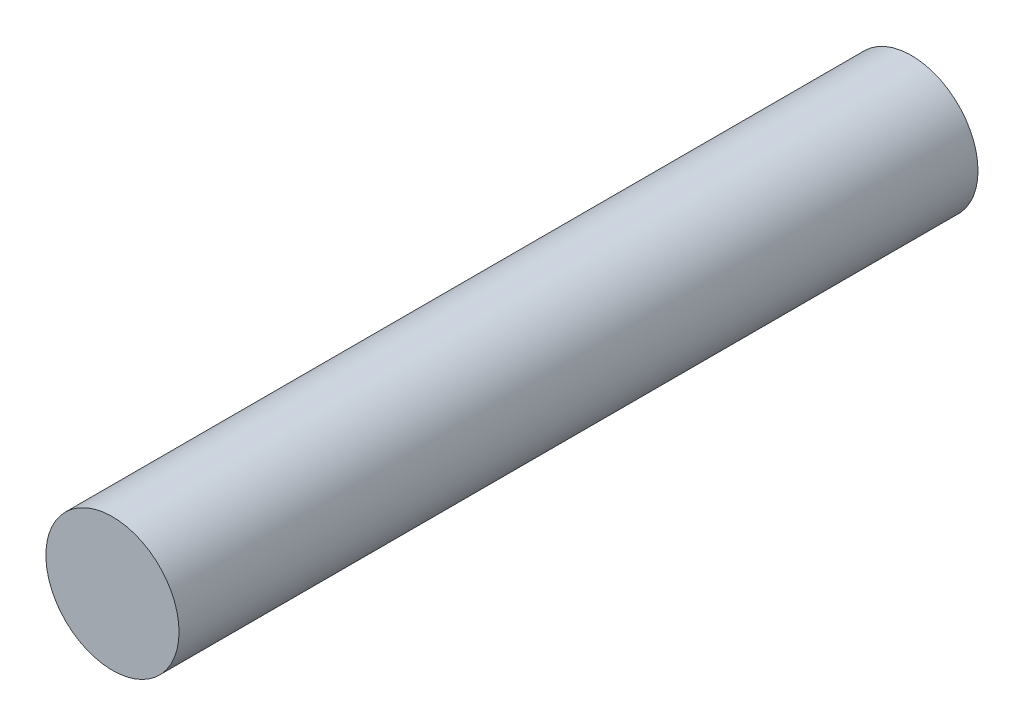
from build123d import *

# Parameters (mm, degrees)
SKETCH1_R           = 1.5875
BOSS_EXTRUDE1_DEPTH = 19.05


with BuildPart() as part:
    # Sketch1 → Boss-Extrude1 (new body)
    with BuildSketch(Plane.XY):
        Circle(SKETCH1_R)
    extrude(amount=BOSS_EXTRUDE1_DEPTH)


solid = part.part
